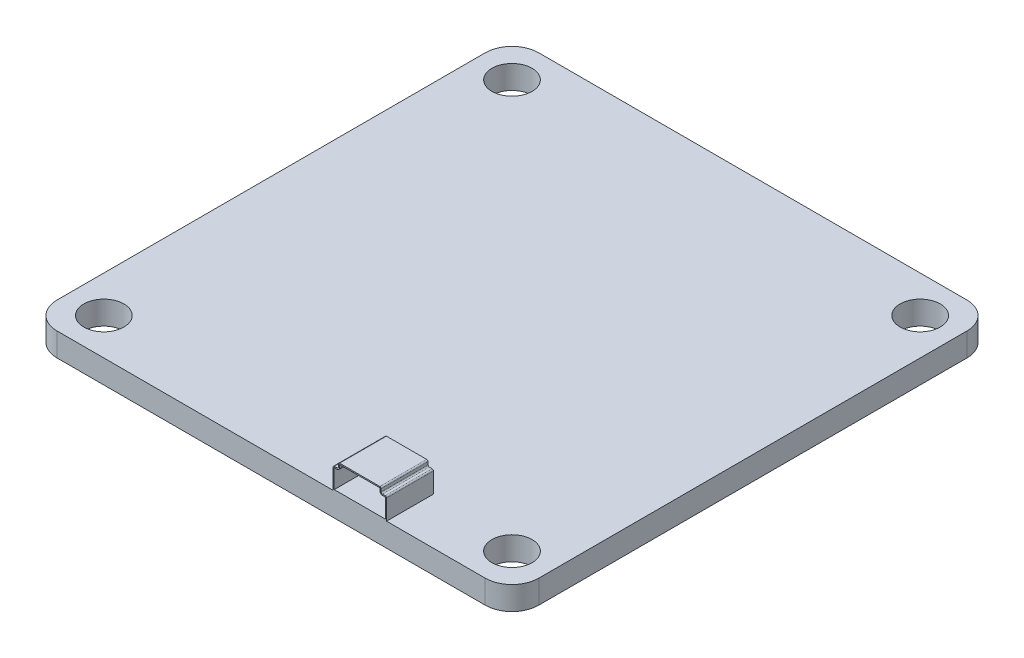
from build123d import *

# Parameters (mm, degrees)
SKETCH1_R           = 1.5
BOSS_EXTRUDE1_DEPTH = 1.75
BOSS_EXTRUDE2_DEPTH = 3
BOSS_EXTRUDE3_DEPTH = 0.5
CUT_EXTRUDE1_REACH  = 5.5
SKETCH4_R           = 0.311736168


with BuildPart() as part:
    # Sketch1 → Boss-Extrude1 (new body)
    with BuildSketch(Plane(origin=(0, 0, 0), x_dir=(1, 0, 0), z_dir=(0, 1, 0))):
        with BuildLine():
            Line((16, -18), (-16, -18))
            ThreePointArc((-16, -18), (-17.414213562, -17.414213562), (-18, -16))
            Line((-18, -16), (-18, 16))
            ThreePointArc((-18, 16), (-17.414213562, 17.414213562), (-16, 18))
            Line((-16, 18), (16, 18))
            ThreePointArc((16, 18), (17.414213562, 17.414213562), (18, 16))
            Line((18, 16), (18, -16))
            ThreePointArc((18, -16), (17.414213562, -17.414213562), (16, -18))
        make_face()
        with Locations((15.25, 15.25)):
            Circle(SKETCH1_R, mode=Mode.SUBTRACT)
        with Locations((-15.25, 15.25)):
            Circle(SKETCH1_R, mode=Mode.SUBTRACT)
        with Locations((15.25, -15.25)):
            Circle(SKETCH1_R, mode=Mode.SUBTRACT)
        with Locations((-15.25, -15.25)):
            Circle(SKETCH1_R, mode=Mode.SUBTRACT)
    extrude(amount=BOSS_EXTRUDE1_DEPTH)

    # Sketch2 → Boss-Extrude2 (add)
    with BuildSketch(Plane.XY.offset(18)):
        with BuildLine():
            Line((4.625773415, 1.75), (8.625773415, 1.75))
            Line((8.625773415, 1.75), (8.625773415, 3.25))
            ThreePointArc((8.625773415, 3.25), (8.596484093, 3.320710678), (8.525773415, 3.35))
            Line((8.525773415, 3.35), (8.325773415, 3.35))
            ThreePointArc((8.325773415, 3.35), (8.255062737, 3.379289322), (8.225773415, 3.45))
            Line((8.225773415, 3.45), (8.225773415, 3.65))
            ThreePointArc((8.225773415, 3.65), (8.196484093, 3.720710678), (8.125773415, 3.75))
            Line((8.125773415, 3.75), (5.125773415, 3.75))
            ThreePointArc((5.125773415, 3.75), (5.055062737, 3.720710678), (5.025773415, 3.65))
            Line((5.025773415, 3.65), (5.025773415, 3.45))
            ThreePointArc((5.025773415, 3.45), (4.996484093, 3.379289322), (4.925773415, 3.35))
            Line((4.925773415, 3.35), (4.725773415, 3.35))
            ThreePointArc((4.725773415, 3.35), (4.655062737, 3.320710678), (4.625773415, 3.25))
            Line((4.625773415, 3.25), (4.625773415, 1.75))
        make_face()
        with BuildLine():
            Line((5.125773415, 3.66), (8.125773415, 3.66))
            ThreePointArc((8.125773415, 3.66), (8.132844483, 3.657071068), (8.135773415, 3.65))
            Line((8.135773415, 3.65), (8.135773415, 3.45))
            ThreePointArc((8.135773415, 3.45), (8.191423127, 3.315649712), (8.325773415, 3.26))
            Line((8.325773415, 3.26), (8.525773415, 3.26))
            ThreePointArc((8.525773415, 3.26), (8.532844483, 3.257071068), (8.535773415, 3.25))
            Line((8.535773415, 3.25), (8.535773415, 1.84))
            Line((8.535773415, 1.84), (4.715773415, 1.84))
            Line((4.715773415, 1.84), (4.715773415, 3.25))
            ThreePointArc((4.715773415, 3.25), (4.718702348, 3.257071068), (4.725773415, 3.26))
            Line((4.725773415, 3.26), (4.925773415, 3.26))
            ThreePointArc((4.925773415, 3.26), (5.060123704, 3.315649712), (5.115773415, 3.45))
            Line((5.115773415, 3.45), (5.115773415, 3.65))
            ThreePointArc((5.115773415, 3.65), (5.118702348, 3.657071068), (5.125773415, 3.66))
        make_face(mode=Mode.SUBTRACT)
    extrude(amount=-BOSS_EXTRUDE2_DEPTH)

    # Sketch3 → Boss-Extrude3 (add)
    with BuildSketch(Plane(origin=(0, 0, 15), x_dir=(-1, 0, 0), z_dir=(0, 0, -1))):
        with BuildLine():
            Line((-4.625773415, 1.75), (-4.625773415, 3.25))
            ThreePointArc((-4.625773415, 3.25), (-4.655062737, 3.320710678), (-4.725773415, 3.35))
            Line((-4.725773415, 3.35), (-4.925773415, 3.35))
            ThreePointArc((-4.925773415, 3.35), (-4.996484093, 3.379289322), (-5.025773415, 3.45))
            Line((-5.025773415, 3.45), (-5.025773415, 3.65))
            ThreePointArc((-5.025773415, 3.65), (-5.055062737, 3.720710678), (-5.125773415, 3.75))
            Line((-5.125773415, 3.75), (-8.125773415, 3.75))
            ThreePointArc((-8.125773415, 3.75), (-8.196484093, 3.720710678), (-8.225773415, 3.65))
            Line((-8.225773415, 3.65), (-8.225773415, 3.45))
            ThreePointArc((-8.225773415, 3.45), (-8.255062737, 3.379289322), (-8.325773415, 3.35))
            Line((-8.325773415, 3.35), (-8.525773415, 3.35))
            ThreePointArc((-8.525773415, 3.35), (-8.596484093, 3.320710678), (-8.625773415, 3.25))
            Line((-8.625773415, 3.25), (-8.625773415, 1.75))
            Line((-8.625773415, 1.75), (-4.625773415, 1.75))
        make_face()
    extrude(amount=BOSS_EXTRUDE3_DEPTH)

    # Sketch4 → Cut-Extrude1 (cut, up to next)
    with BuildSketch(Plane(origin=(0, 0, 14.5), x_dir=(-1, 0, 0), z_dir=(0, 0, -1)), mode=Mode.PRIVATE) as cut_extrude1_sk1:
        with Locations((-5.676091673, 2.531528256)):
            Circle(SKETCH4_R)
    cut_extrude1_tool1 = extrude(cut_extrude1_sk1.sketch, amount=-CUT_EXTRUDE1_REACH, mode=Mode.PRIVATE) & part.part
    add(cut_extrude1_tool1.solids().sort_by_distance((5.676092, 2.531528, 14.5))[0], mode=Mode.SUBTRACT)
    # Sketch4 → Cut-Extrude1 (cut, up to next)
    with BuildSketch(Plane(origin=(0, 0, 14.5), x_dir=(-1, 0, 0), z_dir=(0, 0, -1)), mode=Mode.PRIVATE) as cut_extrude1_sk2:
        with Locations((-7.641197668, 2.531528256)):
            Circle(SKETCH4_R)
    cut_extrude1_tool2 = extrude(cut_extrude1_sk2.sketch, amount=-CUT_EXTRUDE1_REACH, mode=Mode.PRIVATE) & part.part
    add(cut_extrude1_tool2.solids().sort_by_distance((7.641198, 2.531528, 14.5))[0], mode=Mode.SUBTRACT)
    # Sketch4 → Cut-Extrude1 (cut, up to next)
    with BuildSketch(Plane(origin=(0, 0, 14.5), x_dir=(-1, 0, 0), z_dir=(0, 0, -1)), mode=Mode.PRIVATE) as cut_extrude1_sk3:
        with Locations((-6.649897908, 2.531528256)):
            Circle(SKETCH4_R)
    cut_extrude1_tool3 = extrude(cut_extrude1_sk3.sketch, amount=-CUT_EXTRUDE1_REACH, mode=Mode.PRIVATE) & part.part
    add(cut_extrude1_tool3.solids().sort_by_distance((6.649898, 2.531528, 14.5))[0], mode=Mode.SUBTRACT)


solid = part.part
